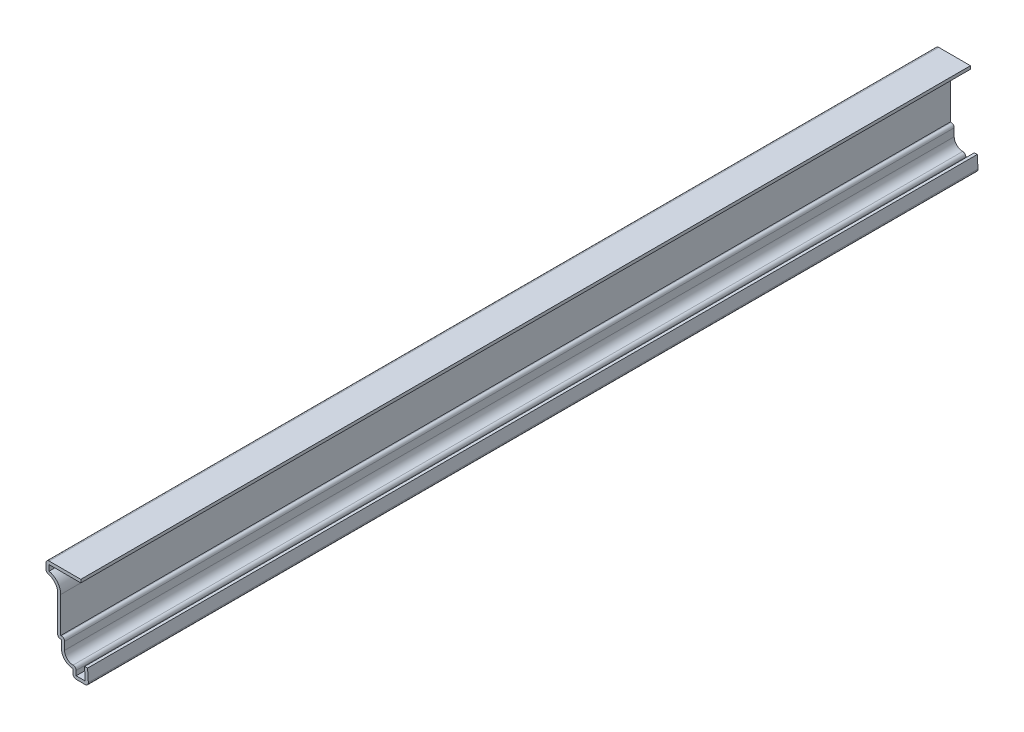
from build123d import *

# Parameters (mm, degrees)
EXTRUDE_THIN1_DEPTH = 365.125
FILLET1_R           = 1.27


with BuildPart() as part:
    # Sketch1 → Extrude-Thin1 (new body)
    with BuildSketch(Plane.XY):
        with BuildLine():
            Line((-0.396875, 6.35), (0, 0))
            Line((0, 0), (-6.35, 0))
            Line((-6.35, 0), (-6.35, 3.175))
            ThreePointArc((-6.35, 3.175), (-9.717596045, 4.569903955), (-11.1125, 7.9375))
            Line((-11.1125, 7.9375), (-11.1125, 11.1125))
            Line((-11.1125, 11.1125), (-12.7, 11.1125))
            Line((-12.7, 11.1125), (-12.7, 26.9875))
            ThreePointArc((-12.7, 26.9875), (-14.094903955, 30.355096045), (-17.4625, 31.75))
            Line((-17.4625, 31.75), (-17.4625, 36.5125))
            Line((-17.4625, 36.5125), (-3.175, 36.5125))
            Line((-3.175, 36.5125), (-3.175, 35.2425))
            Line((-3.175, 35.2425), (-16.1925, 35.2425))
            Line((-16.1925, 35.2425), (-16.1925, 32.88480076))
            ThreePointArc((-16.1925, 32.88480076), (-12.769295804, 30.777604303), (-11.43, 26.9875))
            Line((-11.43, 26.9875), (-11.43, 12.3825))
            Line((-11.43, 12.3825), (-9.8425, 12.3825))
            Line((-9.8425, 12.3825), (-9.8425, 7.9375))
            ThreePointArc((-9.8425, 7.9375), (-8.320035691, 5.053663038), (-5.08, 4.684093132))
            Line((-5.08, 4.684093132), (-5.08, 1.27))
            Line((-5.08, 1.27), (-1.351853051, 1.27))
            Line((-1.351853051, 1.27), (-1.664401775, 6.270779577))
            Line((-1.664401775, 6.270779577), (-0.396875, 6.35))
        make_face()
    extrude(amount=-EXTRUDE_THIN1_DEPTH)

    # Fillet1
    fillet1_edges = [part.edges().sort_by_distance(p)[0] for p in [
        (-9.8425, 12.3825, -182.5625),
        (-5.08, 4.684093132, -182.5625),
        (0, 0, -182.5625),
        (-6.35, 0, -182.5625),
        (-12.7, 11.1125, -182.5625),
        (-17.4625, 31.75, -182.5625),
        (-17.4625, 36.5125, -182.5625),
    ]]
    fillet(fillet1_edges, radius=FILLET1_R)


solid = part.part
